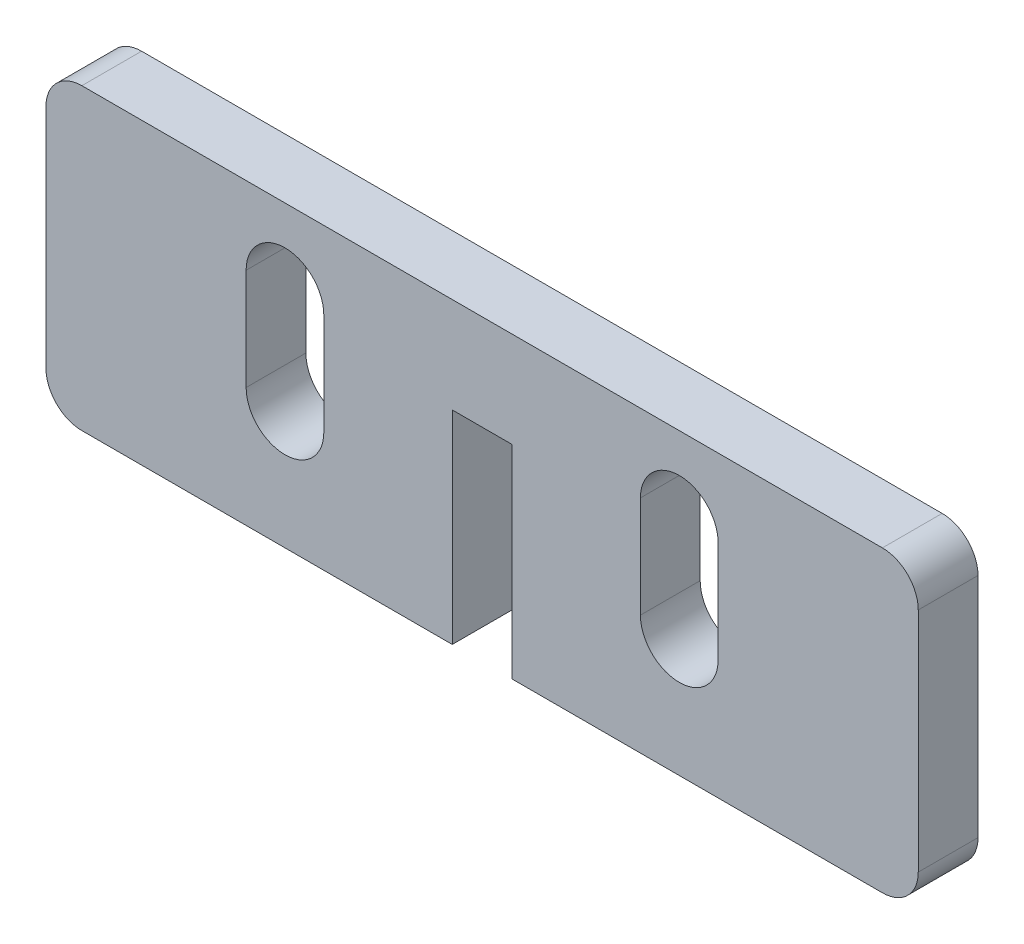
from build123d import *

# Parameters (mm, degrees)
EXTRUDE_1_DEPTH     = 5
SKETCH_3_W          = 5
SKETCH_3_H          = 2
CUT_EXTRUDE_2_DEPTH = 10


with BuildPart() as part:
    # 草图1 → 凸台-拉伸1 (new body)
    with BuildSketch(Plane.XY):
        with BuildLine():
            Line((36.5, -9.5), (36.5, 9.5))
            ThreePointArc((36.5, 9.5), (35.621320344, 11.621320344), (33.5, 12.5))
            Line((33.5, 12.5), (-33.5, 12.5))
            ThreePointArc((-33.5, 12.5), (-35.621320344, 11.621320344), (-36.5, 9.5))
            Line((-36.5, 9.5), (-36.5, -9.5))
            ThreePointArc((-36.5, -9.5), (-35.621320344, -11.621320344), (-33.5, -12.5))
            Line((-33.5, -12.5), (-2.5, -12.5))
            Line((-2.5, -12.5), (-2.5, 2.5))
            Line((-2.5, 2.5), (2.5, 2.5))
            Line((2.5, 2.5), (2.5, -12.5))
            Line((2.5, -12.5), (33.5, -12.5))
            ThreePointArc((33.5, -12.5), (35.621320344, -11.621320344), (36.5, -9.5))
        make_face()
        with BuildLine():
            Line((-19.75, -2.5), (-19.75, 6))
            ThreePointArc((-19.75, 6), (-16.5, 9.25), (-13.25, 6))
            Line((-13.25, 6), (-13.25, -2.5))
            ThreePointArc((-13.25, -2.5), (-16.5, -5.75), (-19.75, -2.5))
        make_face(mode=Mode.SUBTRACT)
        with BuildLine():
            Line((19.75, -2.5), (19.75, 6))
            ThreePointArc((19.75, 6), (16.5, 9.25), (13.25, 6))
            Line((13.25, 6), (13.25, -2.5))
            ThreePointArc((13.25, -2.5), (16.5, -5.75), (19.75, -2.5))
        make_face(mode=Mode.SUBTRACT)
    extrude(amount=EXTRUDE_1_DEPTH)

    # 草图3 → 切除-拉伸2 (cut)
    with BuildSketch(Plane(origin=(0, 0, 0), x_dir=(-1, 0, 0), z_dir=(0, 0, -1))):
        with Locations((0, 3.5)):
            Rectangle(SKETCH_3_W, SKETCH_3_H)
    extrude(amount=-CUT_EXTRUDE_2_DEPTH, mode=Mode.SUBTRACT)


solid = part.part
